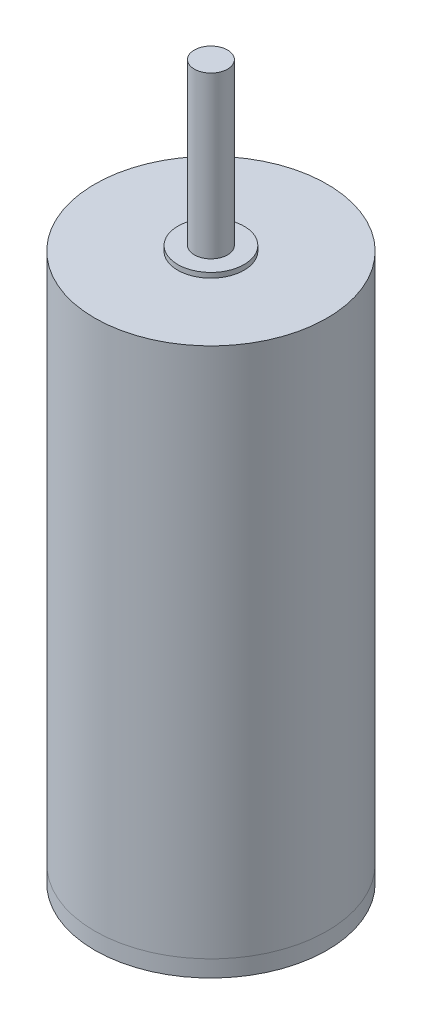
from build123d import *

# Parameters (mm, degrees)
SKETCH1_R           = 3.5
BOSS_EXTRUDE1_DEPTH = 16
SKETCH2_R           = 0.5
BOSS_EXTRUDE2_DEPTH = 5
SKETCH3_R           = 1
BOSS_EXTRUDE3_DEPTH = 0.15
SKETCH1_2_R         = 3.5
BOSS_EXTRUDE4_DEPTH = 0.5


with BuildPart() as part:
    # Sketch1 → Boss-Extrude1 (new body)
    with BuildSketch(Plane(origin=(0, 0, 0), x_dir=(1, 0, 0), z_dir=(0, 1, 0))):
        Circle(SKETCH1_R)
    extrude(amount=BOSS_EXTRUDE1_DEPTH)

    # Sketch2 → Boss-Extrude2 (add)
    with BuildSketch(Plane(origin=(0, 16, 0), x_dir=(1, 0, 0), z_dir=(0, 1, 0))):
        Circle(SKETCH2_R)
    extrude(amount=BOSS_EXTRUDE2_DEPTH)

    # Sketch3 → Boss-Extrude3 (add)
    with BuildSketch(Plane(origin=(0, 16, 0), x_dir=(1, 0, 0), z_dir=(0, 1, 0))):
        Circle(SKETCH3_R)
    extrude(amount=BOSS_EXTRUDE3_DEPTH)


with BuildPart() as body_2:
    # Sketch1_2 → Boss-Extrude4 (new body)
    with BuildSketch(Plane(origin=(0, 0, 0), x_dir=(1, 0, 0), z_dir=(0, 1, 0))):
        Circle(SKETCH1_2_R)
    extrude(amount=-BOSS_EXTRUDE4_DEPTH)


solid = Compound([part.part, body_2.part])
